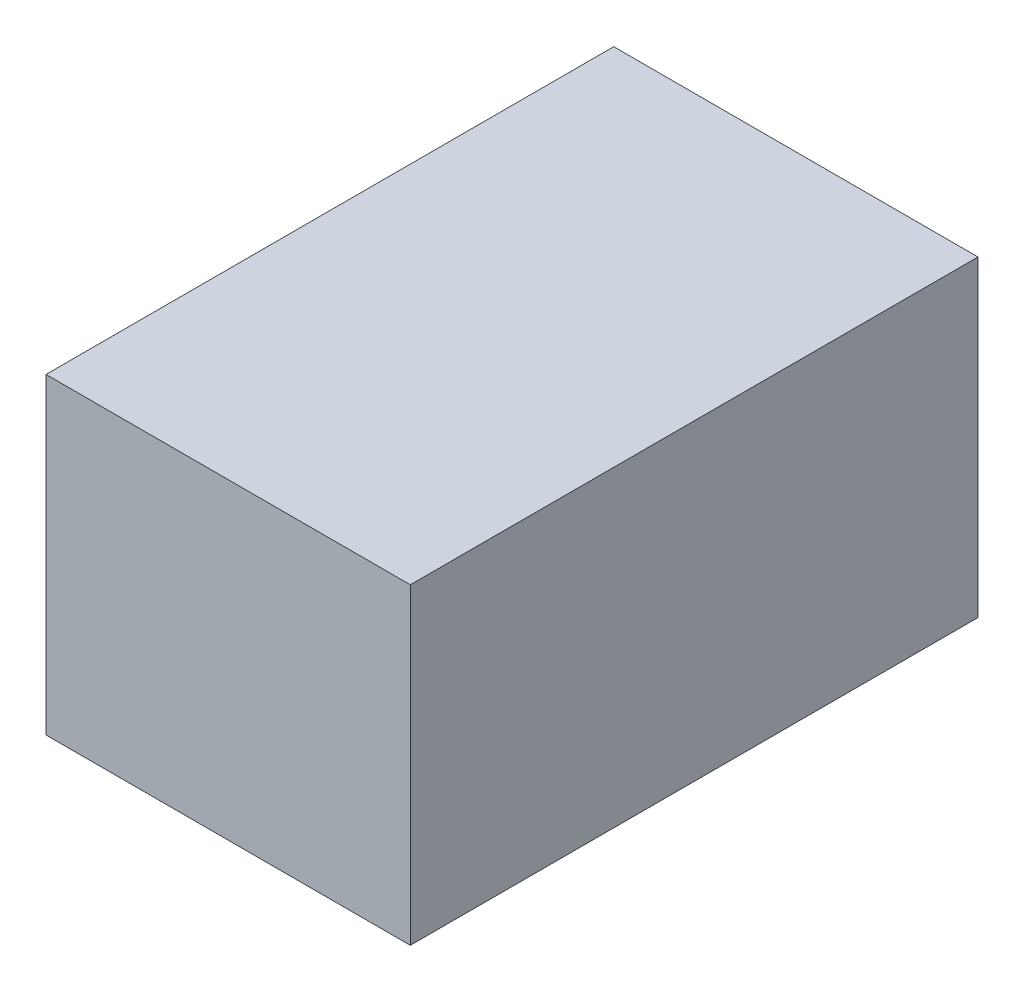
from build123d import *

# Parameters (mm, degrees)
SKETCH_1_W      = 77
SKETCH_1_H      = 66
EXTRUDE_1_DEPTH = 120


with BuildPart() as part:
    # ｽｹｯﾁ1 → ﾎﾞｽ - 押し出し1 (new body)
    with BuildSketch(Plane.XY):
        with Locations((-34.026607289, 31.610606061)):
            Rectangle(SKETCH_1_W, SKETCH_1_H)
    extrude(amount=EXTRUDE_1_DEPTH)


solid = part.part
